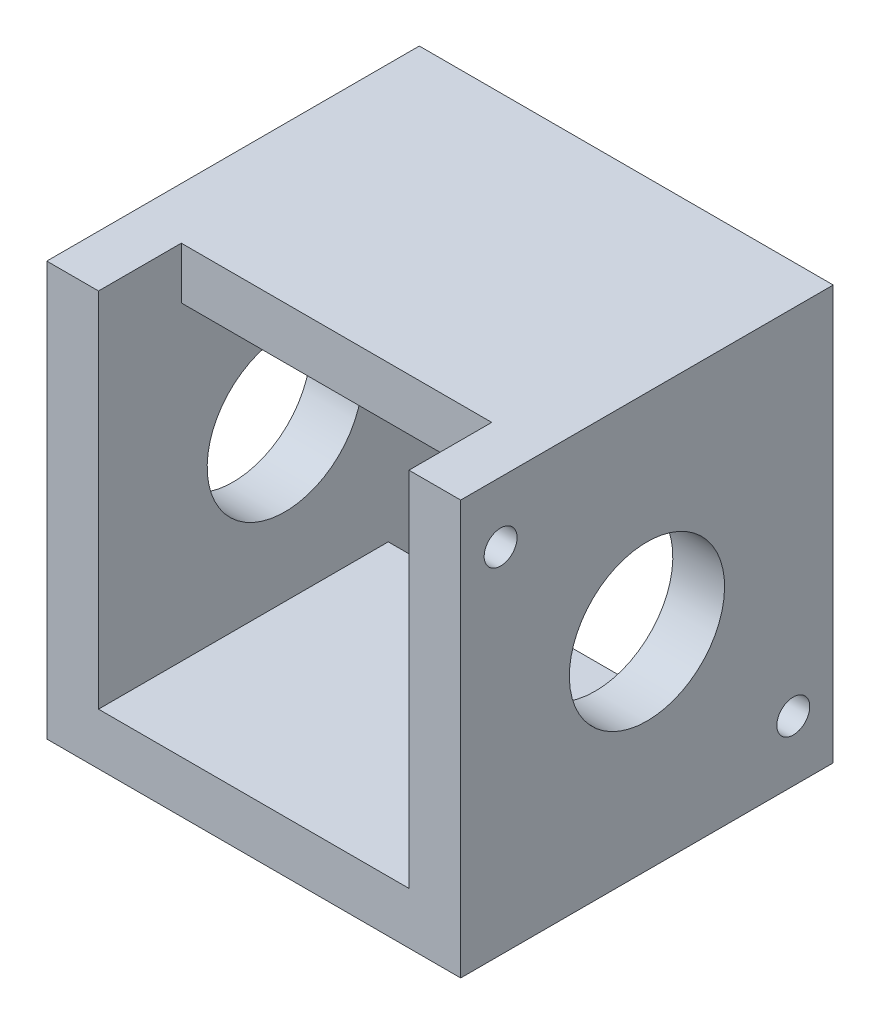
from build123d import *

# Parameters (mm, degrees)
SKETCH1_W                      = 50.8
SKETCH1_H                      = 50.8
SKETCH1_W_2                    = 38.1
SKETCH1_H_2                    = 38.1
EXTRUDE_THIN1_DEPTH            = 45.72
SKETCH2_R                      = 2.0193
CUT_EXTRUDE2_DEPTH             = 1
CUT_EXTRUDE2_DEPTH_BACK        = 6.35
SKETCH4_R                      = 9.525
CUT_EXTRUDE3_DEPTH             = 1
CUT_EXTRUDE3_DEPTH_BACK        = 51.8
CUT_EXTRUDE4_REACH             = 52.8
SKETCH5_W                      = 38.1
SKETCH5_H                      = 10.16
CUT_EXTRUDE4_DIRECTION_2_DEPTH = 1
CUT_EXTRUDE5_START             = -25.4
SKETCH5_3_W                    = 38.1
SKETCH5_3_H                    = 10.16
CUT_EXTRUDE5_DEPTH             = 25.4


with BuildPart() as part:
    # Sketch1 → Extrude-Thin1 (new body)
    with BuildSketch(Plane.XY):
        Rectangle(SKETCH1_W, SKETCH1_H)
        Rectangle(SKETCH1_W_2, SKETCH1_H_2, mode=Mode.SUBTRACT)
    extrude(amount=EXTRUDE_THIN1_DEPTH)

    # Sketch2 → Cut-Extrude2 (cut, two sides)
    with BuildSketch(Plane(origin=(25.4, 0, 0), x_dir=(0, 0, -1), z_dir=(1, 0, 0))) as cut_extrude2_sk:
        with Locations((-40.820512212, 17.96051224)):
            Circle(SKETCH2_R)
        with Locations((-4.899487788, -17.96051224)):
            Circle(SKETCH2_R)
    extrude(amount=CUT_EXTRUDE2_DEPTH, mode=Mode.SUBTRACT)
    extrude(cut_extrude2_sk.sketch, amount=-CUT_EXTRUDE2_DEPTH_BACK, mode=Mode.SUBTRACT)

    # Sketch4 → Cut-Extrude3 (cut, two sides)
    with BuildSketch(Plane(origin=(25.4, 0, 0), x_dir=(0, 0, -1), z_dir=(1, 0, 0))) as cut_extrude3_sk:
        with Locations((-22.86, 0)):
            Circle(SKETCH4_R)
    extrude(amount=CUT_EXTRUDE3_DEPTH, mode=Mode.SUBTRACT)
    extrude(cut_extrude3_sk.sketch, amount=-CUT_EXTRUDE3_DEPTH_BACK, mode=Mode.SUBTRACT)

    # Sketch5 → Cut-Extrude4 (cut, up to next)
    with BuildSketch(Plane.XZ.offset(25.4), mode=Mode.PRIVATE) as cut_extrude4_sk1:
        with Locations((0, 5.08)):
            Rectangle(SKETCH5_W, SKETCH5_H)
    cut_extrude4_tool1 = extrude(cut_extrude4_sk1.sketch, amount=-CUT_EXTRUDE4_REACH, mode=Mode.PRIVATE) & part.part
    add(cut_extrude4_tool1.solids().sort_by_distance((0, -25.4, 5.08))[0], mode=Mode.SUBTRACT)

    # Sketch5 → Cut-Extrude4 direction 2 (cut)
    with BuildSketch(Plane.XZ.offset(25.4)):
        with Locations((0, 5.08)):
            Rectangle(SKETCH5_W, SKETCH5_H)
    extrude(amount=CUT_EXTRUDE4_DIRECTION_2_DEPTH, mode=Mode.SUBTRACT)

    # Sketch5_3 → Cut-Extrude5 (cut)
    with BuildSketch(Plane.XZ.offset(25.4).offset(CUT_EXTRUDE5_START)):
        with Locations((0, 40.64)):
            Rectangle(SKETCH5_3_W, SKETCH5_3_H)
    extrude(amount=-CUT_EXTRUDE5_DEPTH, mode=Mode.SUBTRACT)


solid = part.part
